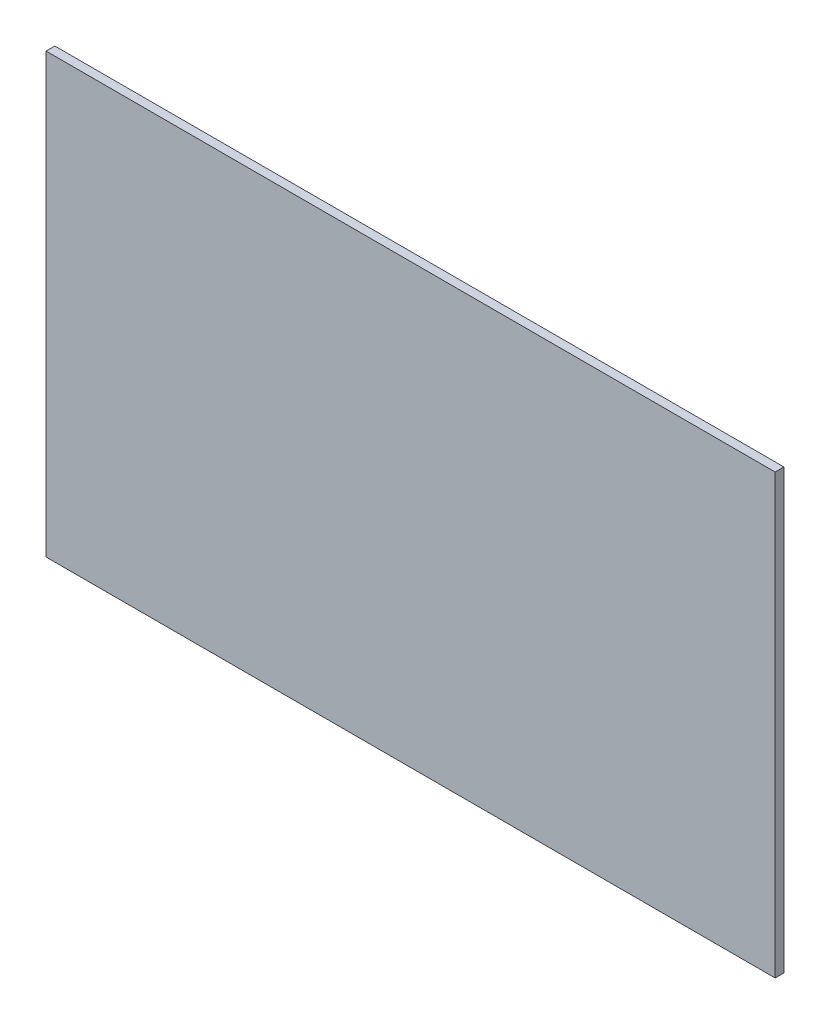
from build123d import *

# Parameters (mm, degrees)
SKETCH1_W           = 249.6
SKETCH1_H           = 150
BOSS_EXTRUDE1_DEPTH = 3


with BuildPart() as part:
    # Sketch1 → Boss-Extrude1 (new body)
    with BuildSketch(Plane.XY):
        with Locations((124.8, -75)):
            Rectangle(SKETCH1_W, SKETCH1_H)
    extrude(amount=BOSS_EXTRUDE1_DEPTH)


solid = part.part
